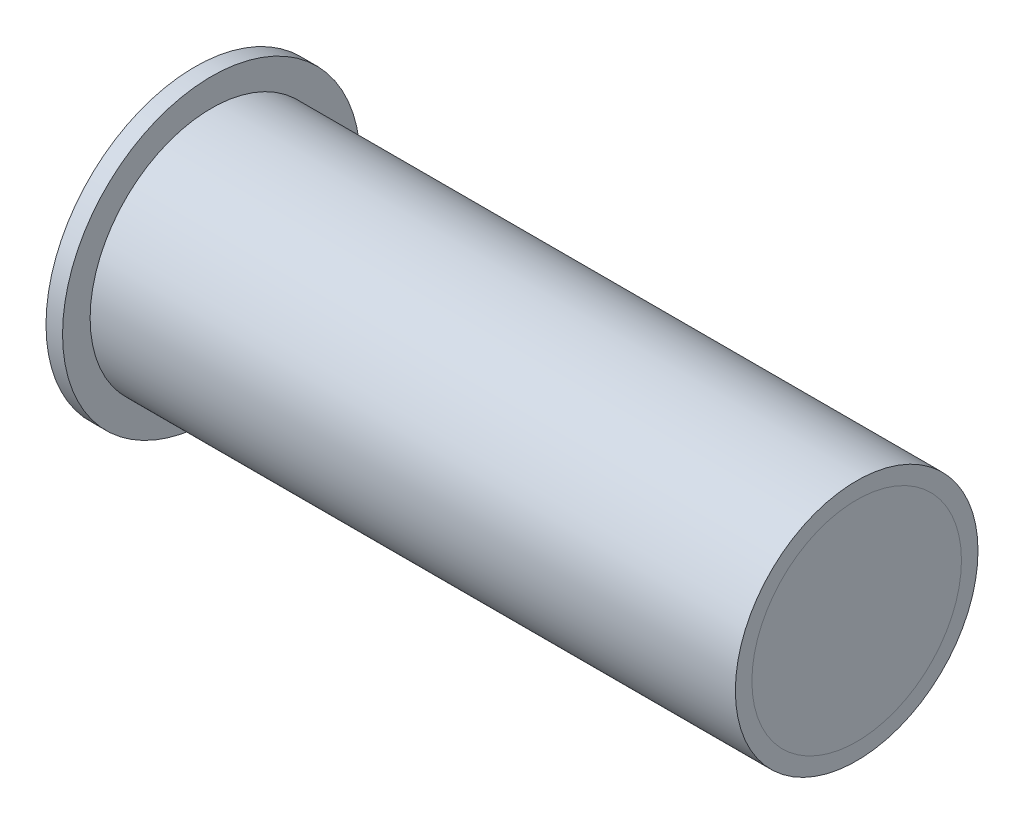
from build123d import *

# Parameters (mm, degrees)
SKETCH2_R           = 19
BOSS_EXTRUDE1_DEPTH = 3
SKETCH3_R           = 19
BOSS_EXTRUDE2_DEPTH = 3


with BuildPart() as part:
    # Sketch1 → Revolve-Thin1 (revolve)
    with BuildSketch(Plane.XY):
        Polygon((203.969675214, 27), (203.969675214, 19), (323.969675214, 19), (323.969675214, 22), (206.969675214, 22), (206.969675214, 27), align=None)
    revolve(axis=Axis((194, 0, 0), (1, 0, 0)))


with BuildPart() as body_2:
    # Sketch2 → Boss-Extrude1 (new body)
    with BuildSketch(Plane.ZY.offset(-203.969675214)):
        Circle(SKETCH2_R)
    extrude(amount=-BOSS_EXTRUDE1_DEPTH)


with BuildPart() as body_3:
    # Sketch3 → Boss-Extrude2 (new body)
    with BuildSketch(Plane(origin=(323.969675214, 0, 0), x_dir=(0, 0, -1), z_dir=(1, 0, 0))):
        Circle(SKETCH3_R)
    extrude(amount=-BOSS_EXTRUDE2_DEPTH)


solid = Compound([part.part, body_2.part, body_3.part])
